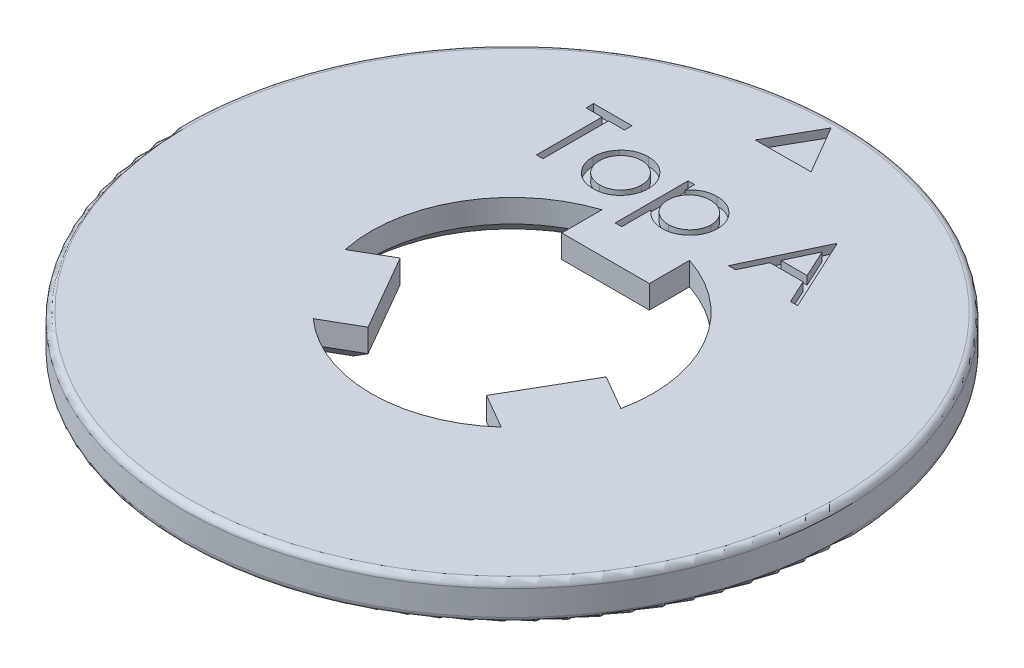
from build123d import *

# Parameters (mm, degrees)
SKETCH1_R           = 15.8
BOSS_EXTRUDE1_DEPTH = 1.8
FILLET1_R           = 0.3
CUT_EXTRUDE1_DEPTH  = 0.4
CUT_EXTRUDE2_DEPTH  = 0.4
SCALE1_SCALE        = 1.15
CHAMFER1_SIZE       = 0.8


with BuildPart() as part:
    # Sketch1 → Boss-Extrude1 (new body)
    with BuildSketch(Plane(origin=(0, 0, 0), x_dir=(1, 0, 0), z_dir=(0, 1, 0))):
        Circle(SKETCH1_R)
        with BuildLine():
            Line((6.606243368, -1.385658169), (4.938104305, -0.422557631))
            Line((4.938104305, -0.422557631), (2.838104305, -4.059864327))
            Line((2.838104305, -4.059864327), (4.508004754, -5.023981801))
            ThreePointArc((4.508004754, -5.023981801), (0.003268724, -6.749999209), (-4.503136859, -5.028345496))
            Line((-4.503136859, -5.028345496), (-2.834997796, -4.065244959))
            Line((-2.834997796, -4.065244959), (-4.934997796, -0.427938263))
            Line((-4.934997796, -0.427938263), (-6.604898245, -1.392055737))
            ThreePointArc((-6.604898245, -1.392055737), (-5.847305152, 3.372168806), (-2.103106509, 6.414003665))
            Line((-2.103106509, 6.414003665), (-2.103106509, 4.48780259))
            Line((-2.103106509, 4.48780259), (2.096893491, 4.48780259))
            Line((2.096893491, 4.48780259), (2.096893491, 6.416037538))
            ThreePointArc((2.096893491, 6.416037538), (5.844036428, 3.377830402), (6.606243368, -1.385658169))
        make_face(mode=Mode.SUBTRACT)
    extrude(amount=BOSS_EXTRUDE1_DEPTH)

    # Fillet1
    fillet1_edges = [part.edges().sort_by_distance(p)[0] for p in [
        (-15.8, 0, 0),
        (-15.8, 1.8, 0),
    ]]
    fillet(fillet1_edges, radius=FILLET1_R)

    # Sketch3 → Cut-Extrude1 (cut)
    with BuildSketch(Plane(origin=(0, 1.8, 0), x_dir=(1, 0, 0), z_dir=(0, 1, 0))):
        Polygon((-1.330846249, 12.985829825), (1.340017361, 13.001714657), (-0.009171112, 15.306807977), align=None)
    extrude(amount=-CUT_EXTRUDE1_DEPTH, mode=Mode.SUBTRACT)

    # Sketch4 → Cut-Extrude2 (cut)
    with BuildSketch(Plane(origin=(0, 1.8, 0), x_dir=(1, 0, 0), z_dir=(0, 1, 0))):
        Polygon((-6.712466694, 10.264172794), (-6.712466694, 10.623147153), (-4.872723104, 10.623147153), (-4.872723104, 10.264172794), (-5.635543617, 10.264172794), (-5.635543617, 7.123147153), (-5.949646181, 7.123147153), (-5.949646181, 10.264172794), align=None)
        with BuildLine():
            add(Edge.make_bspline(
                [(-3.188628553, 9.725711255), (-3.14063728, 9.724689364), (-3.046538122, 9.722685685), (-2.908730236, 9.70127072), (-2.777185101, 9.668523355), (-2.651398908, 9.623251793), (-2.532982613, 9.562569843), (-2.420211369, 9.490160552), (-2.31339436, 9.404377958), (-2.249371331, 9.33801989), (-2.216873745, 9.304337057)],
                knots=[0, 0, 0, 0, 0.000143868, 0.000282091, 0.000417278, 0.000550139, 0.000682145, 0.000815559, 0.000951665, 0.001091969, 0.001091969, 0.001091969, 0.001091969], degree=3))
            add(Edge.make_bspline(
                [(-2.216873745, 9.304337057), (-2.188891791, 9.272123071), (-2.133469411, 9.208318529), (-2.062403692, 9.104862916), (-2.001182132, 8.997722815), (-1.952119171, 8.885475488), (-1.913434147, 8.769100817), (-1.885968451, 8.648198806), (-1.869631516, 8.523036459), (-1.867428549, 8.438032621), (-1.866312848, 8.394982089)],
                knots=[0, 0, 0, 0, 0.000127922, 0.000253368, 0.000375813, 0.000497617, 0.000620225, 0.000743195, 0.000869033, 0.000998161, 0.000998161, 0.000998161, 0.000998161], degree=3))
            add(Edge.make_bspline(
                [(-1.866312848, 8.394982089), (-1.867294185, 8.351682031), (-1.869233353, 8.266119098), (-1.88757697, 8.140099732), (-1.916108056, 8.017904909), (-1.956939894, 7.900046216), (-2.009298003, 7.786163388), (-2.07318869, 7.676753839), (-2.149060308, 7.571601706), (-2.235064304, 7.471599867), (-2.330116181, 7.379433652), (-2.433232329, 7.299105383), (-2.542386363, 7.230283859), (-2.659029716, 7.174847443), (-2.782097203, 7.131137743), (-2.911854271, 7.100437726), (-3.048099341, 7.081876042), (-3.141126563, 7.079492469), (-3.188628553, 7.078275358)],
                knots=[0, 0, 0, 0, 0.000129829, 0.000256548, 0.000381202, 0.000505812, 0.000630045, 0.000756669, 0.000885282, 0.001018518, 0.001151902, 0.001281775, 0.001409974, 0.001538236, 0.001668405, 0.001801048, 0.001937587, 0.002080055, 0.002080055, 0.002080055, 0.002080055], degree=3))
            add(Edge.make_bspline(
                [(-3.188628553, 7.078275358), (-3.236363272, 7.079496554), (-3.329854132, 7.081888329), (-3.466580114, 7.100365611), (-3.596569733, 7.131123594), (-3.719798331, 7.174991087), (-3.836943178, 7.23028563), (-3.946729675, 7.29889732), (-4.049929591, 7.379457475), (-4.145001575, 7.471593412), (-4.231000181, 7.571603369), (-4.306873189, 7.676753407), (-4.370763515, 7.786163501), (-4.423121719, 7.900046186), (-4.463953532, 8.017904917), (-4.492484624, 8.14009973), (-4.510828239, 8.266119098), (-4.512767408, 8.351682031), (-4.513748745, 8.394982089)],
                knots=[0, 0, 0, 0, 0.000143168, 0.000280402, 0.000413045, 0.000543214, 0.000672108, 0.000800903, 0.000930775, 0.00106416, 0.001197395, 0.001326009, 0.001452632, 0.001576866, 0.001701476, 0.00182613, 0.001952849, 0.002082678, 0.002082678, 0.002082678, 0.002082678], degree=3))
            add(Edge.make_bspline(
                [(-4.513748745, 8.394982089), (-4.512625435, 8.437798635), (-4.510401473, 8.522568037), (-4.494080964, 8.647495098), (-4.466722408, 8.768192487), (-4.427991011, 8.884117963), (-4.37847582, 8.995873399), (-4.318114532, 9.10327823), (-4.2463239, 9.20626603), (-4.191121948, 9.26998811), (-4.163187848, 9.302233691)],
                knots=[0, 0, 0, 0, 0.000128428, 0.000254265, 0.000377235, 0.000499178, 0.000620341, 0.000743397, 0.000868267, 0.000996189, 0.000996189, 0.000996189, 0.000996189], degree=3))
            add(Edge.make_bspline(
                [(-4.163187848, 9.302233691), (-4.130739257, 9.336208631), (-4.066923393, 9.403026327), (-3.959574665, 9.488558851), (-3.847080844, 9.562474925), (-3.727355918, 9.62195114), (-3.60167306, 9.668789658), (-3.469453817, 9.701355173), (-3.331178302, 9.722608528), (-3.236618681, 9.724666706), (-3.188628553, 9.725711255)],
                knots=[0, 0, 0, 0, 0.000140798, 0.000276904, 0.000410699, 0.000543958, 0.000677061, 0.000812248, 0.000951858, 0.001095726, 0.001095726, 0.001095726, 0.001095726], degree=3))
        make_face()
        with BuildLine():
            add(Edge.make_bspline(
                [(-3.190030796, 9.411608691), (-3.223968408, 9.4106441), (-3.290967536, 9.408739817), (-3.389587121, 9.394255912), (-3.484527275, 9.371308408), (-3.575968119, 9.338704352), (-3.663601292, 9.296605453), (-3.747510694, 9.244897093), (-3.827943134, 9.184264136), (-3.903325197, 9.114801465), (-3.972507509, 9.03892247), (-4.032985486, 8.958074111), (-4.084410592, 8.873567765), (-4.127250751, 8.785315554), (-4.159157939, 8.69242314), (-4.182330962, 8.595942509), (-4.196801202, 8.495677092), (-4.198687581, 8.427516074), (-4.199646181, 8.392878723)],
                knots=[0, 0, 0, 0, 0.000101781, 0.000200935, 0.000298373, 0.000394396, 0.000491609, 0.000589491, 0.000689611, 0.000793323, 0.000896562, 0.000997243, 0.001095722, 0.001192936, 0.001290943, 0.001389744, 0.001490285, 0.001594167, 0.001594167, 0.001594167, 0.001594167], degree=3))
            add(Edge.make_bspline(
                [(-4.199646181, 8.392878723), (-4.198039357, 8.348126696), (-4.194850113, 8.259302291), (-4.168914876, 8.128491168), (-4.125528597, 8.002909316), (-4.066941317, 7.88329293), (-3.993535098, 7.772620652), (-3.907048031, 7.673949167), (-3.808408331, 7.588763356), (-3.698791831, 7.51808251), (-3.580437513, 7.461922755), (-3.455181192, 7.422123779), (-3.324540498, 7.396252087), (-3.235259767, 7.393680612), (-3.190030796, 7.392377922)],
                knots=[0, 0, 0, 0, 0.000134178, 0.000266319, 0.000398243, 0.00053182, 0.000664828, 0.000795487, 0.000924236, 0.001054533, 0.001185628, 0.001316003, 0.001448011, 0.001583547, 0.001583547, 0.001583547, 0.001583547], degree=3))
            add(Edge.make_bspline(
                [(-3.190030796, 7.392377922), (-3.144804427, 7.393688202), (-3.055528831, 7.396274659), (-2.925069655, 7.421993479), (-2.800155683, 7.46209714), (-2.681924295, 7.518019349), (-2.572357692, 7.589031764), (-2.47300857, 7.673468141), (-2.387259959, 7.772881993), (-2.313926354, 7.883439522), (-2.254379612, 8.002723874), (-2.21119641, 8.128514346), (-2.185198824, 8.259296388), (-2.182017995, 8.348124719), (-2.180415412, 8.392878723)],
                knots=[0, 0, 0, 0, 0.000135536, 0.000267545, 0.000397252, 0.000528347, 0.000658644, 0.000787925, 0.000918122, 0.00105113, 0.001185017, 0.001316942, 0.001449082, 0.00158326, 0.00158326, 0.00158326, 0.00158326], degree=3))
            add(Edge.make_bspline(
                [(-2.180415412, 8.392878723), (-2.181373682, 8.427516281), (-2.183259411, 8.495677707), (-2.197734375, 8.59594016), (-2.220889915, 8.692431757), (-2.252861532, 8.78528376), (-2.295515546, 8.873796265), (-2.347932339, 8.957825992), (-2.408163364, 9.039202538), (-2.478180485, 9.114556178), (-2.553483863, 9.184291215), (-2.633948901, 9.244920604), (-2.71773388, 9.2963782), (-2.805112463, 9.33906444), (-2.89656503, 9.371011781), (-2.99137216, 9.394388412), (-3.089570969, 9.408678609), (-3.156330013, 9.41062575), (-3.190030796, 9.411608691)],
                knots=[0, 0, 0, 0, 0.000103882, 0.000204424, 0.000303225, 0.000401232, 0.000498445, 0.000597291, 0.000697972, 0.000801684, 0.000905395, 0.001005516, 0.001103397, 0.001199979, 0.001296663, 0.00139342, 0.001492573, 0.001593654, 0.001593654, 0.001593654, 0.001593654], degree=3))
        make_face(mode=Mode.SUBTRACT)
        with BuildLine():
            Line((-1.238107719, 9.680839461), (-0.924005155, 9.680839461))
            Line((-0.924005155, 9.680839461), (-0.924005155, 9.207582249))
            add(Edge.make_bspline(
                [(-0.924005155, 9.207582249), (-0.890647671, 9.250519983), (-0.825824077, 9.333960876), (-0.714099172, 9.441951004), (-0.596172363, 9.533026308), (-0.46900895, 9.604408841), (-0.33458526, 9.658229653), (-0.193452943, 9.698009103), (-0.044414178, 9.721450577), (0.057482275, 9.724272239), (0.10944837, 9.725711255)],
                knots=[0, 0, 0, 0, 0.00016294, 0.00031664, 0.000464722, 0.000608822, 0.000752559, 0.000898176, 0.001047911, 0.001203751, 0.001203751, 0.001203751, 0.001203751], degree=3))
            add(Edge.make_bspline(
                [(0.10944837, 9.725711255), (0.154839974, 9.724398077), (0.244558862, 9.721802509), (0.376622091, 9.704229455), (0.503797474, 9.674111762), (0.625365528, 9.630710847), (0.742628593, 9.577055377), (0.853850693, 9.509338342), (0.960764249, 9.430932151), (1.060680438, 9.3407), (1.153001806, 9.243071734), (1.232847987, 9.138049429), (1.301719891, 9.029086843), (1.357390187, 8.914494751), (1.400998535, 8.795175521), (1.432013212, 8.67064708), (1.450470856, 8.54137114), (1.452947308, 8.453468419), (1.454199973, 8.409004525)],
                knots=[0, 0, 0, 0, 0.000136164, 0.000269135, 0.000398888, 0.000527501, 0.000655799, 0.000785059, 0.000917435, 0.001052984, 0.001188402, 0.001319939, 0.001448139, 0.001574506, 0.001701376, 0.001828571, 0.001958859, 0.002092222, 0.002092222, 0.002092222, 0.002092222], degree=3))
            add(Edge.make_bspline(
                [(1.454199973, 8.409004525), (1.452974487, 8.363602216), (1.450557653, 8.274062312), (1.431812647, 8.142575214), (1.401855773, 8.016087841), (1.35879759, 7.894810577), (1.303156101, 7.778826926), (1.235451541, 7.66822053), (1.155565074, 7.563026826), (1.064263946, 7.464673926), (0.96521101, 7.374074613), (0.859333521, 7.294836544), (0.748274595, 7.228295169), (0.632602428, 7.172712209), (0.511326789, 7.130820025), (0.385013512, 7.100602224), (0.253731365, 7.081967729), (0.164430213, 7.079515586), (0.119264075, 7.078275358)],
                knots=[0, 0, 0, 0, 0.000136164, 0.000268535, 0.000397606, 0.000525558, 0.00065382, 0.000782843, 0.000913955, 0.001049409, 0.001184907, 0.001316158, 0.001445417, 0.001572744, 0.001700463, 0.001829535, 0.001961906, 0.002097369, 0.002097369, 0.002097369, 0.002097369], degree=3))
            add(Edge.make_bspline(
                [(0.119264075, 7.078275358), (0.068436504, 7.079570166), (-0.031962853, 7.082127791), (-0.178760523, 7.108047201), (-0.320037375, 7.146784136), (-0.4542282, 7.20348313), (-0.582396012, 7.275738646), (-0.703815818, 7.363848852), (-0.819132571, 7.467629476), (-0.888541328, 7.546361293), (-0.924005155, 7.586588659)],
                knots=[0, 0, 0, 0, 0.000152339, 0.000300914, 0.000445856, 0.000591043, 0.000736709, 0.000886352, 0.001040245, 0.001201023, 0.001201023, 0.001201023, 0.001201023], degree=3))
            Line((-0.924005155, 7.586588659), (-0.924005155, 6.180839461))
            Line((-0.924005155, 6.180839461), (-1.238107719, 6.180839461))
            Line((-1.238107719, 6.180839461), (-1.238107719, 9.680839461))
        make_face()
        with BuildLine():
            add(Edge.make_bspline(
                [(0.106643883, 9.411608691), (0.071064321, 9.410968433), (0.001017333, 9.40970793), (-0.101654886, 9.394733981), (-0.200550314, 9.37299624), (-0.294672265, 9.340084339), (-0.384922882, 9.299685526), (-0.470607046, 9.249203515), (-0.551664614, 9.189551509), (-0.627891644, 9.121872165), (-0.696754938, 9.047297477), (-0.757717866, 8.967709668), (-0.808925171, 8.883209528), (-0.851427191, 8.794584166), (-0.883770474, 8.701138881), (-0.906726194, 8.603405868), (-0.921156546, 8.501278156), (-0.923045484, 8.431722149), (-0.924005155, 8.396384332)],
                knots=[0, 0, 0, 0, 0.000106654, 0.000209973, 0.000310662, 0.000409994, 0.000508521, 0.000606883, 0.00070771, 0.000810012, 0.000912217, 0.001011779, 0.001110258, 0.001208104, 0.001306111, 0.001406276, 0.001508901, 0.001614884, 0.001614884, 0.001614884, 0.001614884], degree=3))
            add(Edge.make_bspline(
                [(-0.924005155, 8.396384332), (-0.922414299, 8.34999622), (-0.919297677, 8.259117979), (-0.893960309, 8.126333857), (-0.852725045, 8.000682201), (-0.794196332, 7.883221164), (-0.720248757, 7.775238329), (-0.631150601, 7.678547723), (-0.52770805, 7.593757132), (-0.411640858, 7.522335878), (-0.287218728, 7.464347811), (-0.157432816, 7.422833601), (-0.024067935, 7.397261373), (0.066100385, 7.394014554), (0.111551736, 7.392377922)],
                knots=[0, 0, 0, 0, 0.000139077, 0.000272463, 0.00040394, 0.000534691, 0.000664794, 0.000795295, 0.000927798, 0.001064768, 0.001203104, 0.001338581, 0.001472656, 0.001608934, 0.001608934, 0.001608934, 0.001608934], degree=3))
            add(Edge.make_bspline(
                [(0.111551736, 7.392377922), (0.156087504, 7.393934299), (0.244482997, 7.397023427), (0.374641118, 7.423761615), (0.501131757, 7.464606639), (0.621311929, 7.524166196), (0.734135417, 7.597156254), (0.83601697, 7.684716287), (0.925023884, 7.78620623), (1.000888239, 7.899214733), (1.062019724, 8.020390117), (1.107949964, 8.145771505), (1.134458537, 8.274916928), (1.138215326, 8.361914641), (1.140097409, 8.405498916)],
                knots=[0, 0, 0, 0, 0.000133479, 0.000264931, 0.000397073, 0.000531279, 0.000666044, 0.000799279, 0.000932907, 0.001069805, 0.001206515, 0.001339137, 0.001469351, 0.001600078, 0.001600078, 0.001600078, 0.001600078], degree=3))
            add(Edge.make_bspline(
                [(1.140097409, 8.405498916), (1.138642675, 8.449353905), (1.135744541, 8.536722208), (1.107197503, 8.665485111), (1.064297526, 8.791373088), (1.001738474, 8.910893637), (0.927537204, 9.02366772), (0.837790207, 9.123221599), (0.737174011, 9.210392272), (0.624484847, 9.282407681), (0.503544421, 9.339693176), (0.376229506, 9.381576815), (0.243185903, 9.406750565), (0.152558249, 9.409975071), (0.106643883, 9.411608691)],
                knots=[0, 0, 0, 0, 0.000131379, 0.000261735, 0.000393889, 0.000529349, 0.000665274, 0.000797853, 0.0009301, 0.001063514, 0.001197743, 0.001330552, 0.001464627, 0.001602305, 0.001602305, 0.001602305, 0.001602305], degree=3))
        make_face(mode=Mode.SUBTRACT)
        Polygon((4.954199973, 10.623147153), (6.569584588, 7.123147153), (6.228138274, 7.123147153), (5.71071039, 8.244942025), (4.124071768, 8.244942025), (3.591920325, 7.123147153), (3.249071768, 7.123147153), (4.909328178, 10.623147153), align=None)
        Polygon((4.928258466, 9.940955646), (4.294444364, 8.603916384), (5.545245646, 8.603916384), align=None, mode=Mode.SUBTRACT)
    extrude(amount=-CUT_EXTRUDE2_DEPTH, mode=Mode.SUBTRACT)


with BuildPart() as part_1:
    # Scale1: scaled about (0.001433912, 0.897000613, 0.042161268)
    add(part.part.scale(SCALE1_SCALE).moved(Location((-0.000215087, -0.134550092, -0.00632419))))

    # Chamfer1
    chamfer1_edges = [part_1.edges().sort_by_distance(p)[0] for p in [
        (-6.724616012, -0.134550092, -3.884318317),
        (-6.63565531, -0.134550092, 1.040172359),
        (-4.467962552, -0.134550092, 2.577256162),
        (-4.219642513, -0.134550092, 5.222490321),
        (0.003543946, -0.134550092, 7.7561749),
        (4.223797622, -0.134550092, 5.216887334),
        (4.471104863, -0.134550092, 2.571068436),
        (6.637784825, -0.134550092, 1.033399895),
        (6.720426805, -0.134550092, -3.890829153),
        (2.411212428, -0.134550092, -6.276032264),
        (-0.003787572, -0.134550092, -5.167297169),
        (-2.418787572, -0.134550092, -6.274862787),
    ]]
    chamfer(chamfer1_edges, length=CHAMFER1_SIZE)


solid = part_1.part
